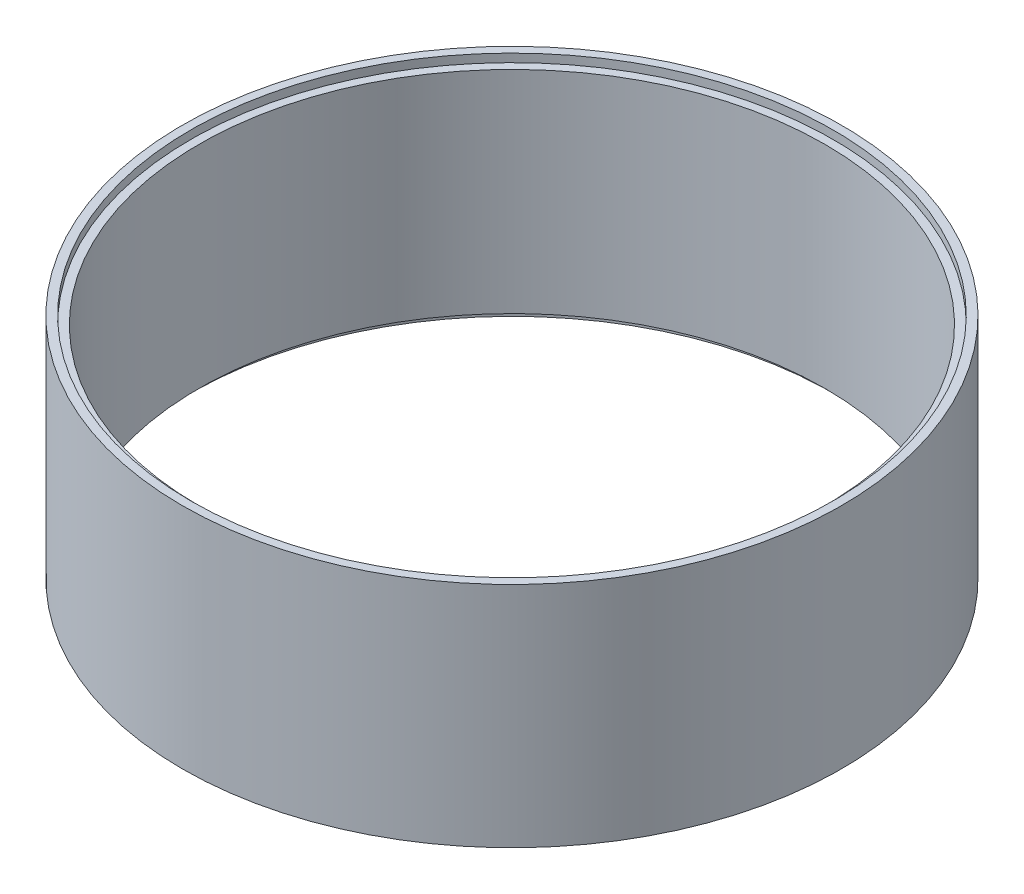
from build123d import *

# Parameters (mm, degrees)
ESQUISSE2_R             = 159
ESQUISSE2_R_2           = 151
BOSS_EXTRU_1_DEPTH      = 55
ESQUISSE3_R             = 155
ENL_V_MAT_EXTRU_1_DEPTH = 4


with BuildPart() as part:
    # Esquisse2 → Boss.-Extru.1 (new body, symmetric)
    with BuildSketch(Plane(origin=(0, 0, 0), x_dir=(1, 0, 0), z_dir=(0, 1, 0))):
        Circle(ESQUISSE2_R)
        Circle(ESQUISSE2_R_2, mode=Mode.SUBTRACT)
    extrude(amount=BOSS_EXTRU_1_DEPTH, both=True)

    # Esquisse3 → Enlèv. mat.-Extru.1 (cut)
    with BuildSketch(Plane(origin=(0, 55, 0), x_dir=(1, 0, 0), z_dir=(0, 1, 0))):
        Circle(ESQUISSE3_R)
    enl_v_mat_extru_1 = extrude(amount=-ENL_V_MAT_EXTRU_1_DEPTH, mode=Mode.SUBTRACT)

    # Symétrie1: Enlèv. mat.-Extru.1 across plane
    add(enl_v_mat_extru_1.mirror(Plane.ZX), mode=Mode.SUBTRACT)


solid = part.part
